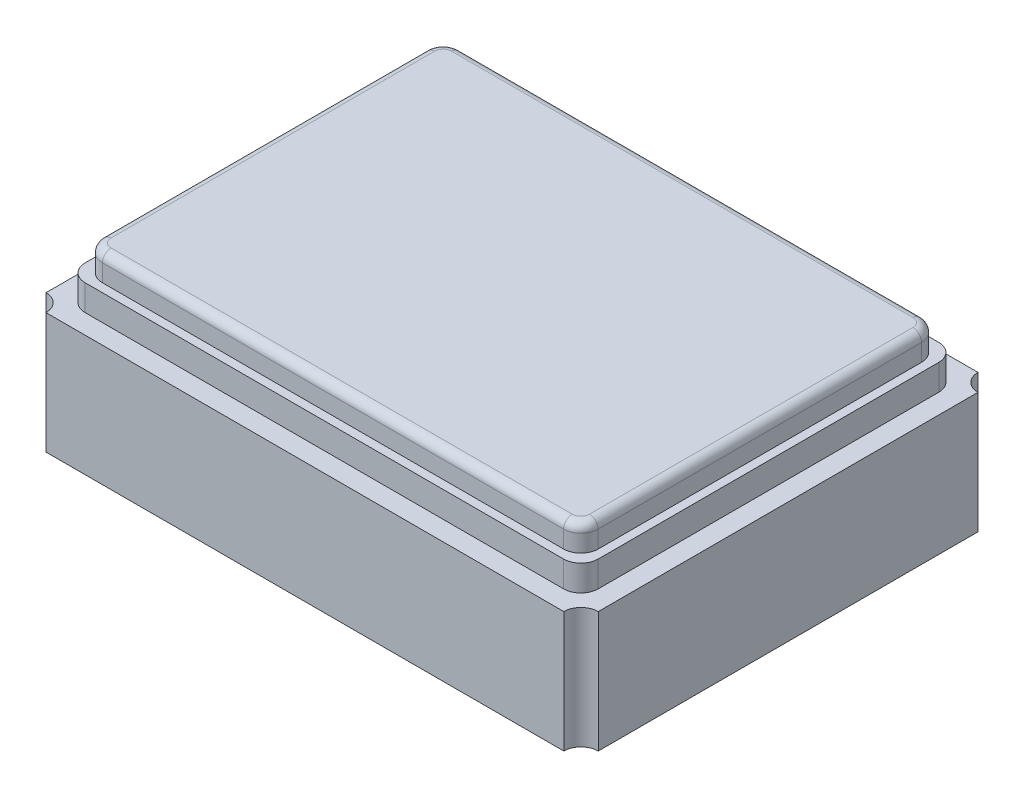
from build123d import *

# Parameters (mm, degrees)
SKETCH1_W           = 3.2
SKETCH1_H           = 2.4
BOSS_EXTRUDE1_DEPTH = 0.7
SKETCH2_R           = 0.1
CUT_EXTRUDE1_DEPTH  = 1.7
BOSS_EXTRUDE2_DEPTH = 0.15
BOSS_EXTRUDE3_DEPTH = 0.15
FILLET1_R           = 0.05


with BuildPart() as part:
    # Sketch1 → Boss-Extrude1 (new body)
    with BuildSketch(Plane(origin=(0, 0, 0), x_dir=(1, 0, 0), z_dir=(0, 1, 0))):
        Rectangle(SKETCH1_W, SKETCH1_H)
    extrude(amount=BOSS_EXTRUDE1_DEPTH)

    # Sketch2 → Cut-Extrude1 (cut, through all)
    with BuildSketch(Plane(origin=(0, 0.7, 0), x_dir=(1, 0, 0), z_dir=(0, 1, 0))):
        with Locations((-1.6, 1.2)):
            Circle(SKETCH2_R)
        with Locations((1.6, 1.2)):
            Circle(SKETCH2_R)
        with Locations((1.6, -1.2)):
            Circle(SKETCH2_R)
        with Locations((-1.6, -1.2)):
            Circle(SKETCH2_R)
    extrude(amount=-CUT_EXTRUDE1_DEPTH, mode=Mode.SUBTRACT)


with BuildPart() as body_2:
    # Sketch3 → Boss-Extrude2 (new body)
    with BuildSketch(Plane(origin=(0, 0.7, 0), x_dir=(1, 0, 0), z_dir=(0, 1, 0))):
        with BuildLine():
            Line((-1.386096781, -1.0868469), (1.386096781, -1.0868469))
            ThreePointArc((1.386096781, -1.0868469), (1.456807459, -1.057557578), (1.486096781, -0.9868469))
            Line((1.486096781, -0.9868469), (1.486096781, 0.9868469))
            ThreePointArc((1.486096781, 0.9868469), (1.456807459, 1.057557578), (1.386096781, 1.0868469))
            Line((1.386096781, 1.0868469), (-1.386096781, 1.0868469))
            ThreePointArc((-1.386096781, 1.0868469), (-1.456807459, 1.057557578), (-1.486096781, 0.9868469))
            Line((-1.486096781, 0.9868469), (-1.486096781, -0.9868469))
            ThreePointArc((-1.486096781, -0.9868469), (-1.456807459, -1.057557578), (-1.386096781, -1.0868469))
        make_face()
    extrude(amount=BOSS_EXTRUDE2_DEPTH)


with BuildPart() as body_3:
    # Sketch4 → Boss-Extrude3 (new body)
    with BuildSketch(Plane(origin=(0, 0.85, 0), x_dir=(1, 0, 0), z_dir=(0, 1, 0))):
        with BuildLine():
            Line((-1.336096781, -1.0368469), (1.336096781, -1.0368469))
            ThreePointArc((1.336096781, -1.0368469), (1.406807459, -1.007557578), (1.436096781, -0.9368469))
            Line((1.436096781, -0.9368469), (1.436096781, 0.9368469))
            ThreePointArc((1.436096781, 0.9368469), (1.406807459, 1.007557578), (1.336096781, 1.0368469))
            Line((1.336096781, 1.0368469), (-1.336096781, 1.0368469))
            ThreePointArc((-1.336096781, 1.0368469), (-1.406807459, 1.007557578), (-1.436096781, 0.9368469))
            Line((-1.436096781, 0.9368469), (-1.436096781, -0.9368469))
            ThreePointArc((-1.436096781, -0.9368469), (-1.406807459, -1.007557578), (-1.336096781, -1.0368469))
        make_face()
    extrude(amount=BOSS_EXTRUDE3_DEPTH)

    # Fillet1
    fillet1_edges = [body_3.edges().sort_by_distance(p)[0] for p in [
        (1.406807459, 1, 1.007557578),
        (1.436096781, 1, 0),
        (1.406807459, 1, -1.007557578),
        (0, 1, -1.0368469),
        (-1.406807459, 1, -1.007557578),
        (-1.436096781, 1, 0),
        (-1.406807459, 1, 1.007557578),
        (0, 1, 1.0368469),
    ]]
    fillet(fillet1_edges, radius=FILLET1_R)


solid = Compound([part.part, body_2.part, body_3.part])
